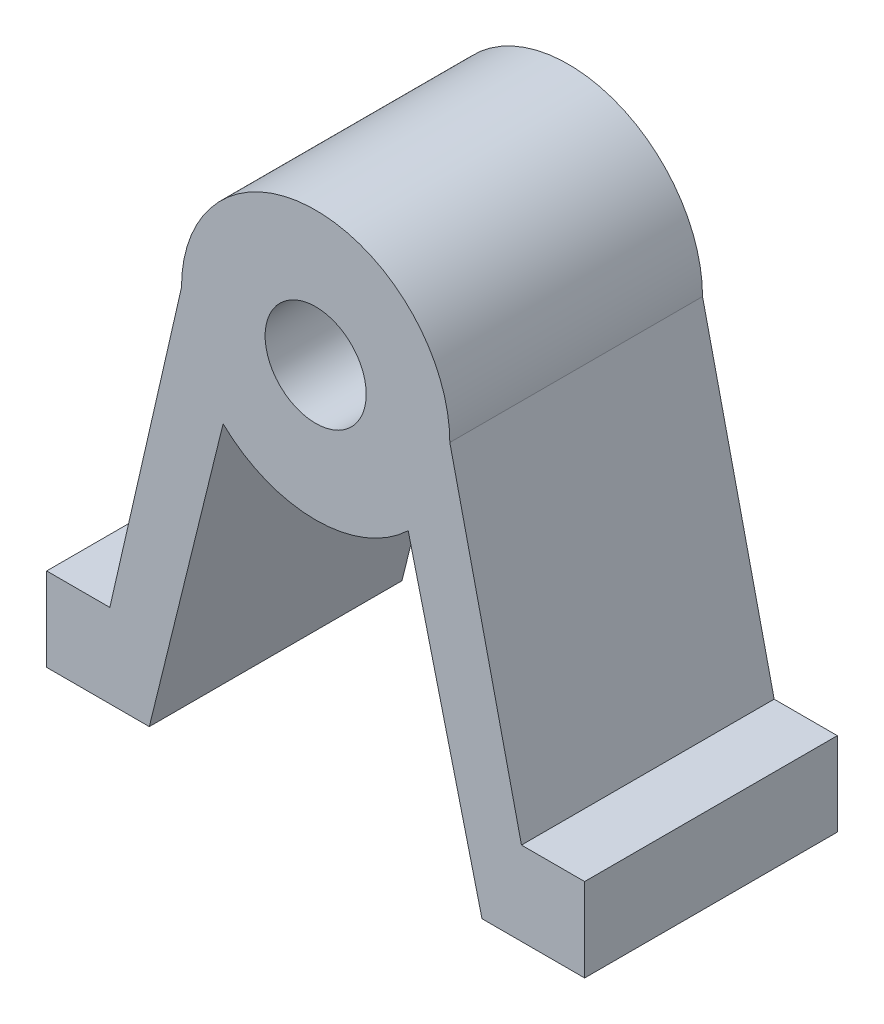
from build123d import *

# Parameters (mm, degrees)
SKETCH_1_R      = 4
EXTRUDE_1_DEPTH = 20


with BuildPart() as part:
    # 草图1 → 凸台-拉伸1 (new body)
    with BuildSketch(Plane.XY):
        with BuildLine():
            Line((-37.719289559, 36.699716541), (-32.049702854, 11.94104698))
            Line((-32.049702854, 11.94104698), (-27.049702854, 11.94104698))
            Line((-27.049702854, 11.94104698), (-27.049702854, 5.329716541))
            Line((-27.049702854, 5.329716541), (-35.173631719, 5.329716541))
            Line((-35.173631719, 5.329716541), (-41.015175762, 29.009348728))
            ThreePointArc((-41.015175762, 29.009348728), (-48.339289559, 26.079716541), (-55.663403355, 29.009348728))
            Line((-55.663403355, 29.009348728), (-61.504947398, 5.329716541))
            Line((-61.504947398, 5.329716541), (-69.628876263, 5.329716541))
            Line((-69.628876263, 5.329716541), (-69.628876263, 11.94104698))
            Line((-69.628876263, 11.94104698), (-64.628876263, 11.94104698))
            Line((-64.628876263, 11.94104698), (-58.959289559, 36.699716541))
            ThreePointArc((-58.959289559, 36.699716541), (-48.339289559, 47.319716541), (-37.719289559, 36.699716541))
        make_face()
        with Locations((-48.339289559, 36.699716541)):
            Circle(SKETCH_1_R, mode=Mode.SUBTRACT)
    extrude(amount=EXTRUDE_1_DEPTH)


solid = part.part
